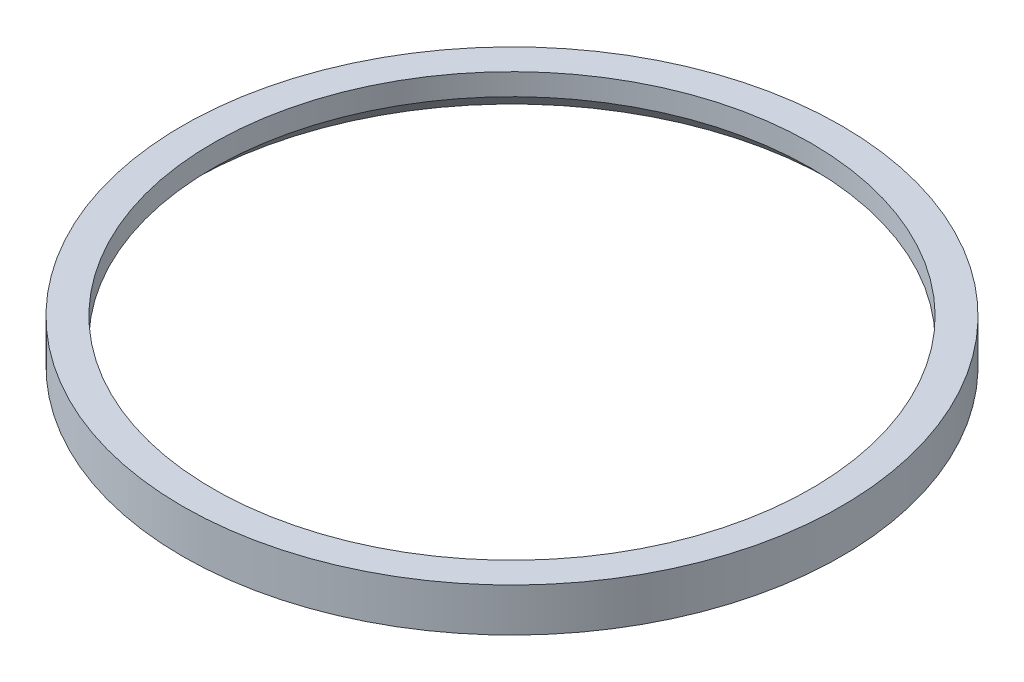
from build123d import *


with BuildPart() as part:
    # Sketch1 → Revolve1 (revolve)
    with BuildSketch(Plane(origin=(0, 0, 0), x_dir=(0, 0, -1), z_dir=(1, 0, 0))):
        Polygon((18.5, 0), (19, 0), (19, 2.5), (17.25, 2.5), (17.25, 1.25), align=None)
    revolve(axis=Axis((0, 0, 0), (0, 1, 0)))


solid = part.part
